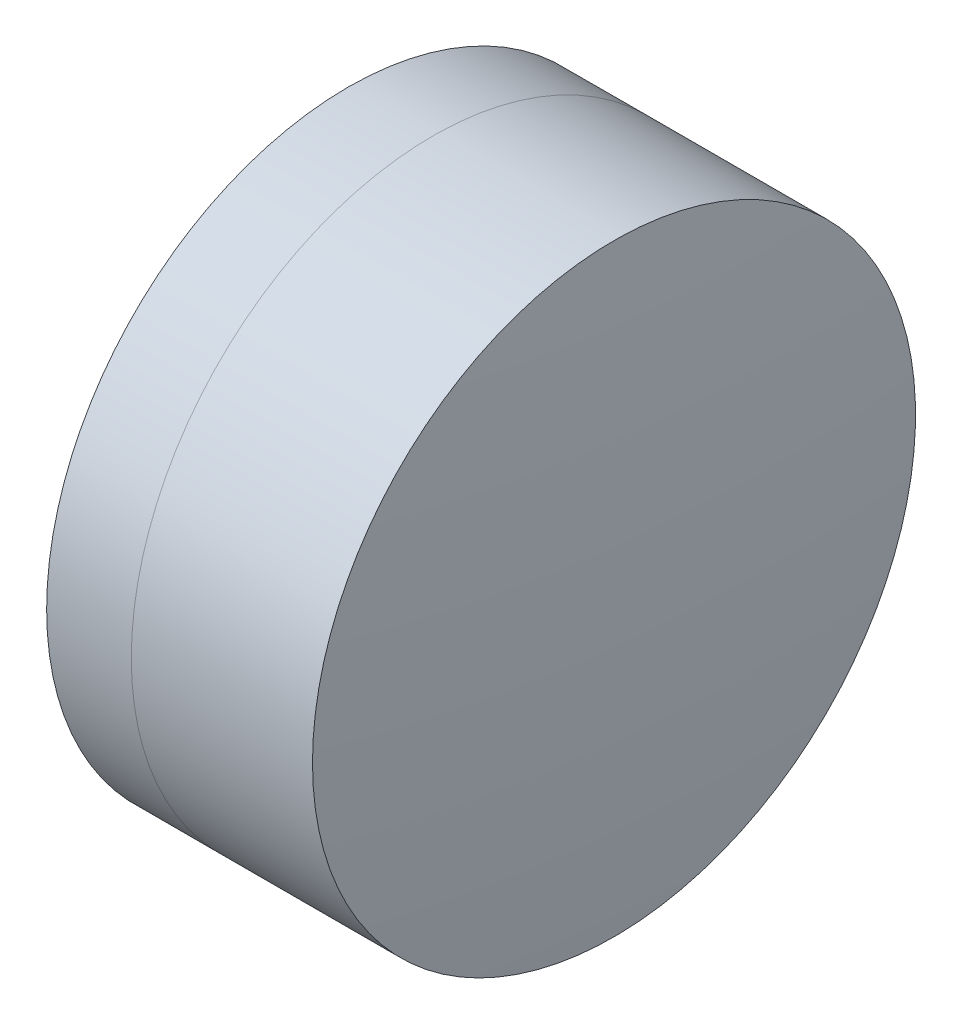
from build123d import *


with BuildPart() as part:
    # 草图1 one side → 旋转1 (revolve)
    with BuildSketch(Plane(origin=(0, 0, 0), x_dir=(1, 0, 0), z_dir=(0, 1, 0)), mode=Mode.PRIVATE) as revolve_1_sk:
        with BuildLine():
            ThreePointArc((-2.417297295, 6.35), (-3.243892922, 3.222702498), (-3.522170847, 0))
            Line((-3.522170847, 0), (1.477829153, 0))
            ThreePointArc((1.477829153, 0), (0.935845916, 3.346087086), (-0.634680052, 6.35))
            Line((-0.634680052, 6.35), (-2.417297295, 6.35))
        make_face()
    revolve(revolve_1_sk.sketch.rotate(Axis((-9.702612178, 0, 0), (1, 0, 0)), 180), axis=Axis((-9.702612178, 0, 0), (1, 0, 0)))  # turned: the seam where the file's is


with BuildPart() as body_2:
    # 草图2 one side → 旋转3 (revolve)
    with BuildSketch(Plane(origin=(0, 0, 0), x_dir=(1, 0, 0), z_dir=(0, 1, 0)), mode=Mode.PRIVATE) as revolve_3_sk:
        with BuildLine():
            Line((3.18112922, 6.35), (-0.634680052, 6.35))
            ThreePointArc((-0.634680052, 6.35), (0.935845916, 3.346087086), (1.477829153, 0))
            Line((1.477829153, 0), (3.477829153, 0))
            ThreePointArc((3.477829153, 0), (3.40361373, 3.178463892), (3.18112922, 6.35))
        make_face()
    revolve(revolve_3_sk.sketch.rotate(Axis((-0.551919993, 0, 0), (1, 0, 0)), 180), axis=Axis((-0.551919993, 0, 0), (1, 0, 0)))  # turned: the seam where the file's is


solid = Compound([part.part, body_2.part])
